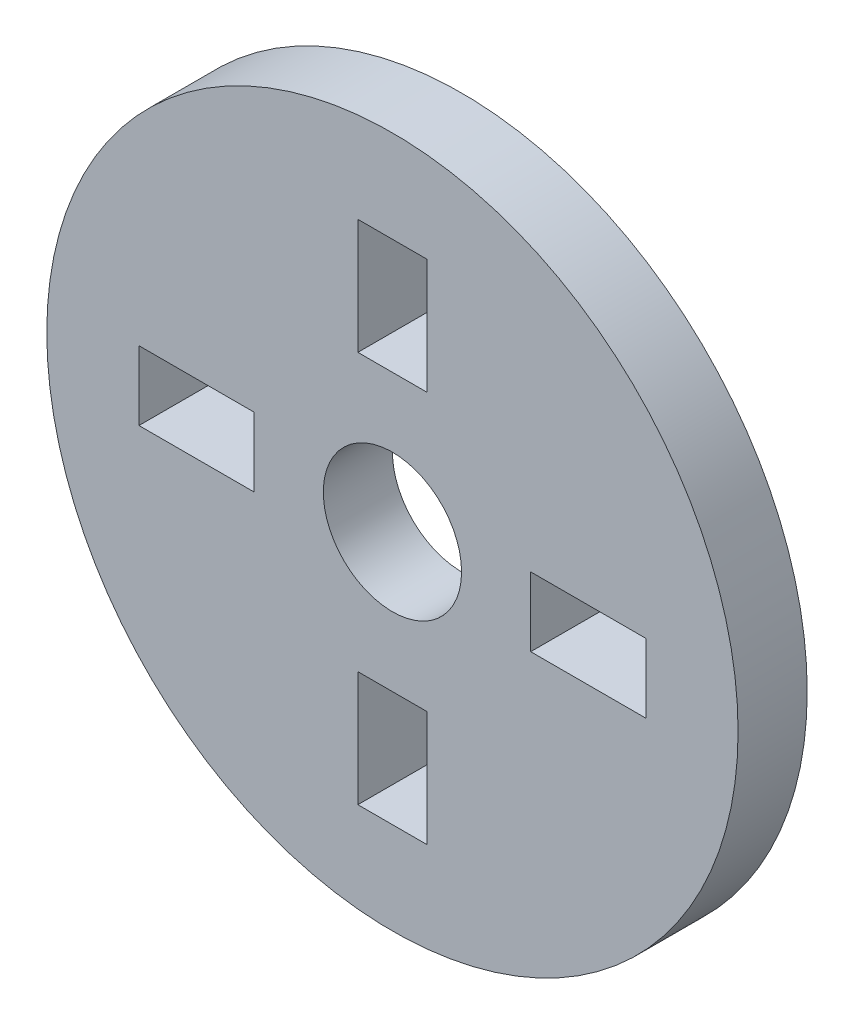
from build123d import *

# Parameters (mm, degrees)
SKETCH1_R           = 15
SKETCH1_R_2         = 3
BOSS_EXTRUDE1_DEPTH = 3
SKETCH2_W           = 5
SKETCH2_H           = 3
SKETCH2_W_2         = 3
SKETCH2_H_2         = 5
CUT_EXTRUDE1_DEPTH  = 3


with BuildPart() as part:
    # Sketch1 → Boss-Extrude1 (new body)
    with BuildSketch(Plane.XY):
        Circle(SKETCH1_R)
        Circle(SKETCH1_R_2, mode=Mode.SUBTRACT)
    extrude(amount=BOSS_EXTRUDE1_DEPTH)

    # Sketch2 → Cut-Extrude1 (cut)
    with BuildSketch(Plane.XY.offset(3)):
        with Locations((8.5, 0)):
            Rectangle(SKETCH2_W, SKETCH2_H)
        with Locations((0, 8.5)):
            Rectangle(SKETCH2_W_2, SKETCH2_H_2)
        with Locations((0, -8.5)):
            Rectangle(SKETCH2_W_2, SKETCH2_H_2)
        with Locations((-8.5, 0)):
            Rectangle(SKETCH2_W, SKETCH2_H)
    extrude(amount=-CUT_EXTRUDE1_DEPTH, mode=Mode.SUBTRACT)


solid = part.part
